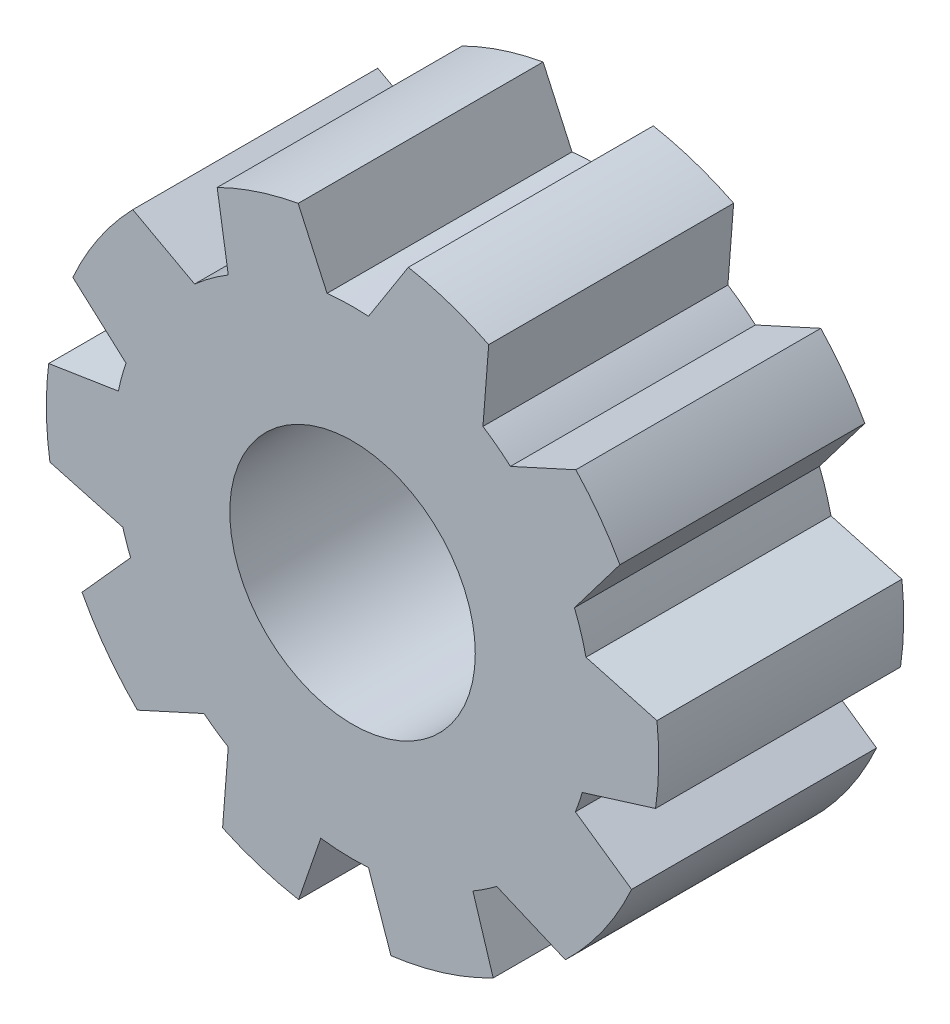
from build123d import *

# Parameters (mm, degrees)
SKETCH1_R           = 6.35
BOSS_EXTRUDE1_DEPTH = 5.08
SKETCH2_R           = 2.545711461
CUT_EXTRUDE1_DEPTH  = 5.08
CUT_EXTRUDE4_DEPTH  = 5.08


with BuildPart() as part:
    # Sketch1 → Boss-Extrude1 (new body)
    with BuildSketch(Plane.XY):
        Circle(SKETCH1_R)
    extrude(amount=BOSS_EXTRUDE1_DEPTH)

    # Sketch2 → Cut-Extrude1 (cut)
    with BuildSketch(Plane.XY.offset(5.08)):
        Circle(SKETCH2_R)
    extrude(amount=-CUT_EXTRUDE1_DEPTH, mode=Mode.SUBTRACT)

    # Sketch6 → Cut-Extrude4 (cut)
    with BuildSketch(Plane(origin=(0, 0, 0), x_dir=(-1, 0, 0), z_dir=(0, 0, -1))):
        with BuildLine():
            Line((-6.313419859, 0.680609785), (-4.841727293, 1.082552663))
            ThreePointArc((-4.841727293, 1.082552663), (-4.737782551, 1.472297507), (-4.602520026, 1.852310143))
            Line((-4.602520026, 1.852310143), (-5.544711841, 3.094942746))
            ThreePointArc((-5.544711841, 3.094942746), (-6.050708452, 1.926506484), (-6.313419859, 0.680609785))
        make_face()
        with BuildLine():
            ThreePointArc((-4.621895526, -1.803420416), (-4.697643554, -1.595740734), (-4.764064977, -1.384892901))
            Line((-4.764064977, -1.384892901), (-6.284089397, -0.912535181))
            ThreePointArc((-6.284089397, -0.912535181), (-6.095179755, -1.780809857), (-5.786915427, -2.614213043))
            Line((-5.786915427, -2.614213043), (-4.621895526, -1.803420416))
        make_face()
        with BuildLine():
            ThreePointArc((-2.49633596, -4.287487636), (-2.747933203, -4.130751331), (-2.989720929, -3.959269152))
            Line((-2.989720929, -3.959269152), (-4.414172057, -4.564820375))
            ThreePointArc((-4.414172057, -4.564820375), (-3.704724213, -5.157278207), (-2.916783485, -5.640467543))
            Line((-2.916783485, -5.640467543), (-2.49633596, -4.287487636))
        make_face()
        with BuildLine():
            ThreePointArc((0.658971441, -4.91731635), (0.164985262, -4.958530358), (-0.330647946, -4.950243972))
            Line((-0.330647946, -4.950243972), (-0.797062617, -6.299777074))
            ThreePointArc((-0.797062617, -6.299777074), (0.162157154, -6.347929194), (1.117667403, -6.250865506))
            Line((1.117667403, -6.250865506), (0.658971441, -4.91731635))
        make_face()
        with BuildLine():
            ThreePointArc((3.079848524, -3.889572794), (2.834017843, -4.072172186), (2.577390132, -4.23925743))
            Line((2.577390132, -4.23925743), (2.695058949, -5.74970932))
            ThreePointArc((2.695058949, -5.74970932), (3.630700167, -5.209656063), (4.461255519, -4.518816127))
            Line((4.461255519, -4.518816127), (3.079848524, -3.889572794))
        make_face()
        with BuildLine():
            ThreePointArc((4.764064977, -1.384892901), (4.689120213, -1.620615648), (4.602520026, -1.852310143))
            Line((4.602520026, -1.852310143), (5.609586886, -2.975741079))
            ThreePointArc((5.609586886, -2.975741079), (6.026210342, -2.001821398), (6.2751364, -0.972195025))
            Line((6.2751364, -0.972195025), (4.764064977, -1.384892901))
        make_face()
        with BuildLine():
            ThreePointArc((4.697742855, 1.595448377), (4.785985372, 1.307129477), (4.856550498, 1.013982598))
            Line((4.856550498, 1.013982598), (6.301072583, 0.786755552))
            ThreePointArc((6.301072583, 0.786755552), (6.117140529, 1.703846165), (5.800483524, 2.583968051))
            Line((5.800483524, 2.583968051), (4.697742855, 1.595448377))
        make_face()
        with BuildLine():
            Line((-4.631054346, 4.34463297), (-3.274854363, 3.726871658))
            ThreePointArc((-3.274854363, 3.726871658), (-2.997527533, 3.953362131), (-2.704587495, 4.159260744))
            Line((-2.704587495, 4.159260744), (-2.823654461, 5.68765993))
            ThreePointArc((-2.823654461, 5.68765993), (-3.787360718, 5.096900901), (-4.631054346, 4.34463297))
        make_face()
        with BuildLine():
            Line((-1.15729269, 6.243650665), (-0.330647946, 4.950243972))
            ThreePointArc((-0.330647946, 4.950243972), (0.099169547, 4.960283142), (0.528242314, 4.933072421))
            Line((0.528242314, 4.933072421), (1.127688946, 6.249065341))
            ThreePointArc((1.127688946, 6.249065341), (-0.015047428, 6.349982171), (-1.15729269, 6.243650665))
        make_face()
        with BuildLine():
            Line((2.80655769, 5.696115688), (2.577390132, 4.23925743))
            ThreePointArc((2.577390132, 4.23925743), (2.937316156, 3.998301796), (3.274854363, 3.726871658))
            Line((3.274854363, 3.726871658), (4.557114361, 4.422127169))
            ThreePointArc((4.557114361, 4.422127169), (3.736532912, 5.134279092), (2.80655769, 5.696115688))
        make_face()
    extrude(amount=-CUT_EXTRUDE4_DEPTH, mode=Mode.SUBTRACT)


solid = part.part
